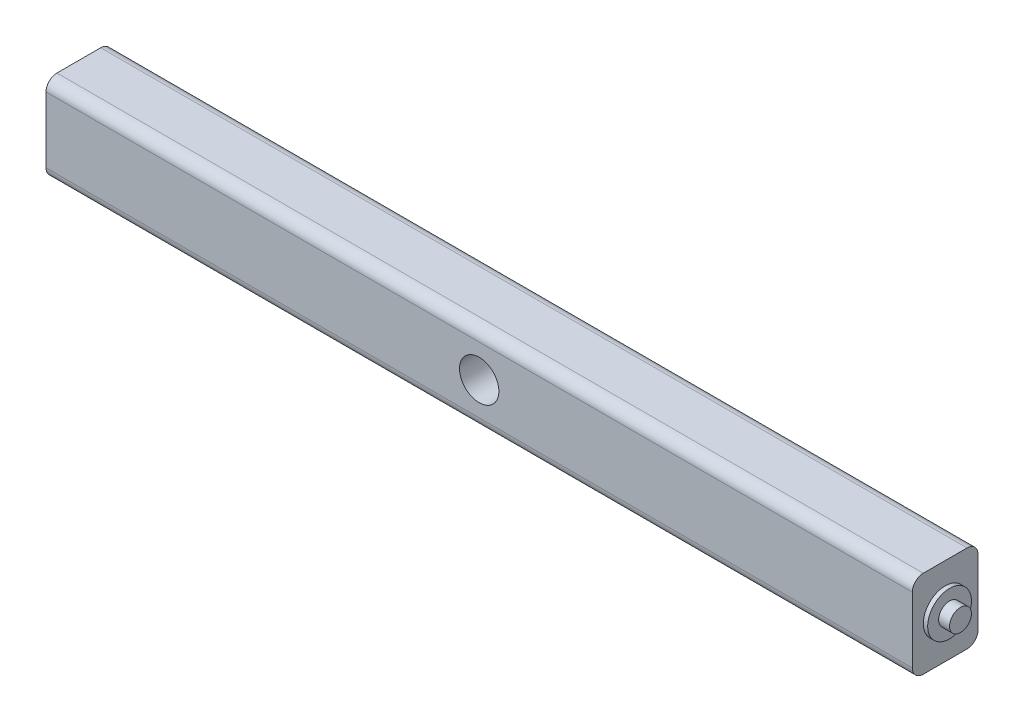
from build123d import *

# Parameters (mm, degrees)
SKETCH1_R           = 10
BOSS_EXTRUDE1_DEPTH = 205
SKETCH2_R           = 12.5
SKETCH2_R_2         = 5
CUT_EXTRUDE1_DEPTH  = 5
SKETCH3_W           = 40
SKETCH3_H           = 40
BOSS_EXTRUDE5_DEPTH = 15
SKETCH4_R           = 9
CUT_EXTRUDE2_DEPTH  = 15
FILLET2_R           = 2
SKETCH5_W           = 30
SKETCH5_H           = 40
BOSS_EXTRUDE6_DEPTH = 178
SKETCH6_W           = 30
SKETCH6_H           = 40
BOSS_EXTRUDE7_DEPTH = 178
FILLET3_R           = 5


with BuildPart() as part:
    # Sketch1 → Boss-Extrude1 (new body, symmetric)
    with BuildSketch(Plane(origin=(0, 0, 0), x_dir=(0, 0, -1), z_dir=(1, 0, 0))):
        Circle(SKETCH1_R)
    extrude(amount=BOSS_EXTRUDE1_DEPTH, both=True)

    # Sketch2 → Cut-Extrude1 (cut)
    with BuildSketch(Plane.ZY.offset(205)):
        Circle(SKETCH2_R)
        Circle(SKETCH2_R_2, mode=Mode.SUBTRACT)
    cut_extrude1 = extrude(amount=-CUT_EXTRUDE1_DEPTH, mode=Mode.SUBTRACT)

    # Mirror1: Cut-Extrude1 across plane
    add(cut_extrude1.mirror(Plane(origin=(0, 0, 0), x_dir=(0, 0, 1), z_dir=(1, 0, 0))), mode=Mode.SUBTRACT)

    # Sketch3 → Boss-Extrude5 (add, symmetric)
    with BuildSketch(Plane.XY):
        Rectangle(SKETCH3_W, SKETCH3_H)
    extrude(amount=BOSS_EXTRUDE5_DEPTH, both=True)

    # Sketch4 → Cut-Extrude2 (cut, symmetric)
    with BuildSketch(Plane.XY):
        Circle(SKETCH4_R)
    extrude(amount=CUT_EXTRUDE2_DEPTH, both=True, mode=Mode.SUBTRACT)

    # Fillet2
    fillet2_edges = [part.edges().sort_by_distance(p)[0] for p in [
        (-20, 0, 10),
        (20, 0, 10),
    ]]
    fillet(fillet2_edges, radius=FILLET2_R)

    # Sketch5 → Boss-Extrude6 (add)
    with BuildSketch(Plane.ZY.offset(20)):
        Rectangle(SKETCH5_W, SKETCH5_H)
    extrude(amount=BOSS_EXTRUDE6_DEPTH)

    # Sketch6 → Boss-Extrude7 (add)
    with BuildSketch(Plane(origin=(20, 0, 0), x_dir=(0, 0, -1), z_dir=(1, 0, 0))):
        Rectangle(SKETCH6_W, SKETCH6_H)
    extrude(amount=BOSS_EXTRUDE7_DEPTH)

    # Fillet3
    fillet3_edges = [part.edges().sort_by_distance(p)[0] for p in [
        (0, -20, -15),
        (0, 20, 15),
        (0, -20, 15),
        (0, 20, -15),
    ]]
    fillet(fillet3_edges, radius=FILLET3_R)


solid = part.part
